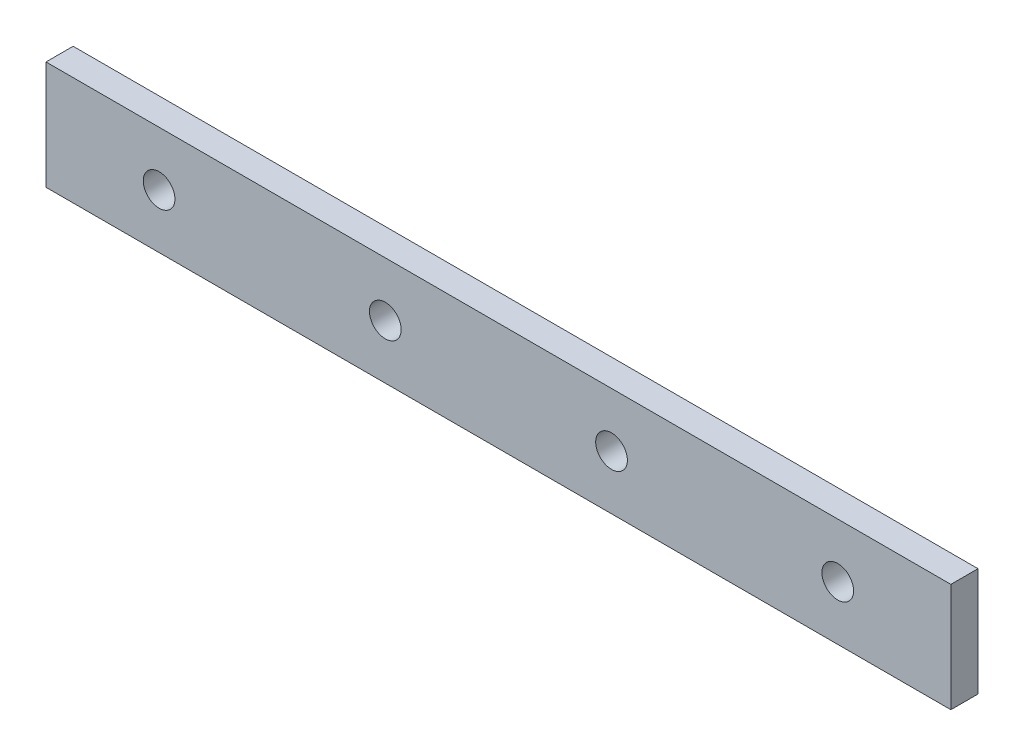
from build123d import *

# Parameters (mm, degrees)
SKETCH1_W           = 100
SKETCH1_H           = 12
BOSS_EXTRUDE1_DEPTH = 3
SKETCH7_R           = 1.75
CUT_EXTRUDE1_DEPTH  = 4
LPATTERN1_COUNT     = 4
LPATTERN1_PITCH     = 25


with BuildPart() as part:
    # Sketch1 → Boss-Extrude1 (new body)
    with BuildSketch(Plane.XY):
        Rectangle(SKETCH1_W, SKETCH1_H)
    extrude(amount=BOSS_EXTRUDE1_DEPTH)

    # Sketch7 → Cut-Extrude1 (cut, through all)
    with BuildSketch(Plane.XY.offset(3)):
        with Locations((37.5, 0)):
            Circle(SKETCH7_R)
    cut_extrude1 = extrude(amount=-CUT_EXTRUDE1_DEPTH, mode=Mode.SUBTRACT)

    # LPattern1: Cut-Extrude1 ×4
    with Locations(*[(-i * LPATTERN1_PITCH, 0, 0) for i in range(1, LPATTERN1_COUNT)]):
        add(cut_extrude1, mode=Mode.SUBTRACT)


solid = part.part
